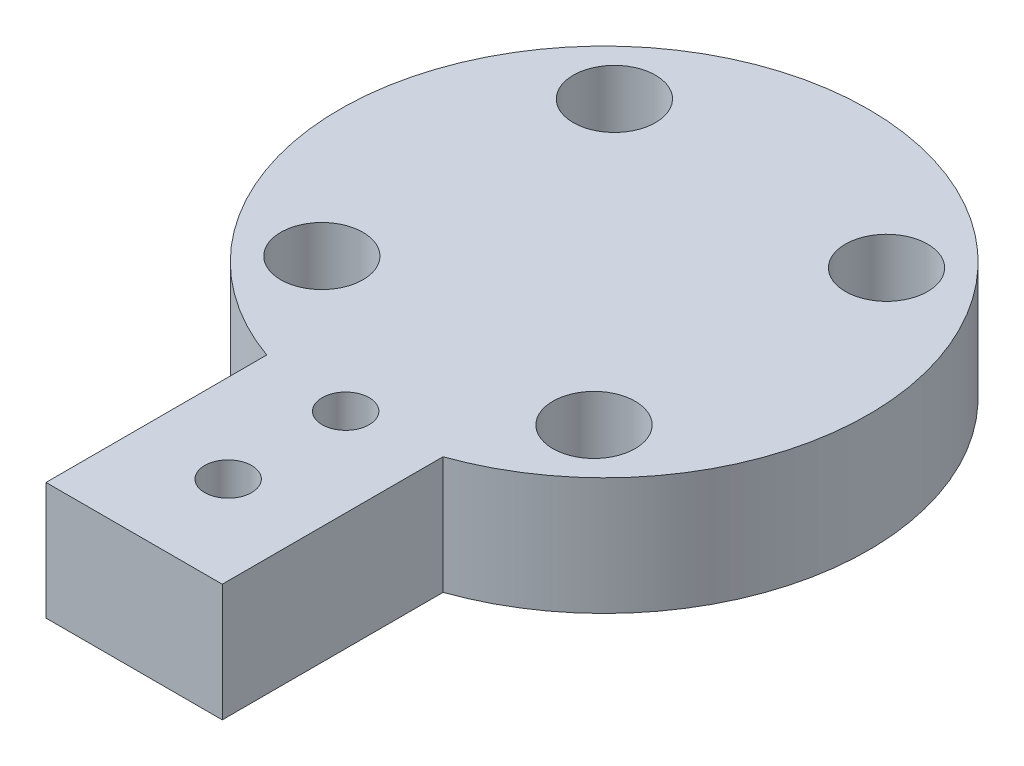
from build123d import *

# Parameters (mm, degrees)
BOSS_EXTRUDE1_DEPTH = 10
SKETCH2_R           = 2
CUT_EXTRUDE1_DEPTH  = 10
SKETCH3_R           = 2
CUT_EXTRUDE2_DEPTH  = 10
SKETCH4_R           = 3.5
CUT_EXTRUDE3_DEPTH  = 5


with BuildPart() as part:
    # Sketch1 → Boss-Extrude1 (new body)
    with BuildSketch(Plane(origin=(0, 0, 0), x_dir=(1, 0, 0), z_dir=(0, 1, 0))):
        with BuildLine():
            ThreePointArc((7.5, -21.213203436), (0, -22.5), (-7.5, -21.213203436))
            Line((-7.5, -21.213203436), (-7.5, -40))
            Line((-7.5, -40), (7.5, -40))
            Line((7.5, -40), (7.5, -21.213203436))
        make_face()
        with BuildLine():
            Line((-7.5, -21.213203436), (-7.5, 0))
            Line((-7.5, 0), (7.5, 0))
            Line((7.5, 0), (7.5, -21.213203436))
            ThreePointArc((7.5, -21.213203436), (18.371173071, -12.990381057), (22.5, 0))
            ThreePointArc((22.5, 0), (-12.990381057, 18.371173071), (-7.5, -21.213203436))
        make_face()
        with BuildLine():
            Line((7.5, 0), (-7.5, 0))
            Line((-7.5, 0), (-7.5, -21.213203436))
            ThreePointArc((-7.5, -21.213203436), (0, -22.5), (7.5, -21.213203436))
            Line((7.5, -21.213203436), (7.5, 0))
        make_face()
    extrude(amount=BOSS_EXTRUDE1_DEPTH)

    # Sketch2 → Cut-Extrude1 (cut)
    with BuildSketch(Plane(origin=(0, 10, 0), x_dir=(1, 0, 0), z_dir=(0, 1, 0))):
        with Locations((-11.579332818, 12.446648203)):
            Circle(SKETCH2_R)
        with Locations((12.446648203, 11.579332818)):
            Circle(SKETCH2_R)
        with Locations((11.579332818, -12.446648203)):
            Circle(SKETCH2_R)
        with Locations((-12.446648203, -11.579332818)):
            Circle(SKETCH2_R)
    extrude(amount=-CUT_EXTRUDE1_DEPTH, mode=Mode.SUBTRACT)

    # Sketch3 → Cut-Extrude2 (cut)
    with BuildSketch(Plane(origin=(0, 10, 0), x_dir=(1, 0, 0), z_dir=(0, 1, 0))):
        with Locations((0, -22)):
            Circle(SKETCH3_R)
        with Locations((0, -32)):
            Circle(SKETCH3_R)
    extrude(amount=-CUT_EXTRUDE2_DEPTH, mode=Mode.SUBTRACT)

    # Sketch4 → Cut-Extrude3 (cut)
    with BuildSketch(Plane(origin=(0, 10, 0), x_dir=(1, 0, 0), z_dir=(0, 1, 0))):
        with Locations((-11.579332818, 12.446648203)):
            Circle(SKETCH4_R)
        with Locations((12.446648203, 11.579332818)):
            Circle(SKETCH4_R)
        with Locations((11.579332818, -12.446648203)):
            Circle(SKETCH4_R)
        with Locations((-12.446648203, -11.579332818)):
            Circle(SKETCH4_R)
    extrude(amount=-CUT_EXTRUDE3_DEPTH, mode=Mode.SUBTRACT)


solid = part.part
